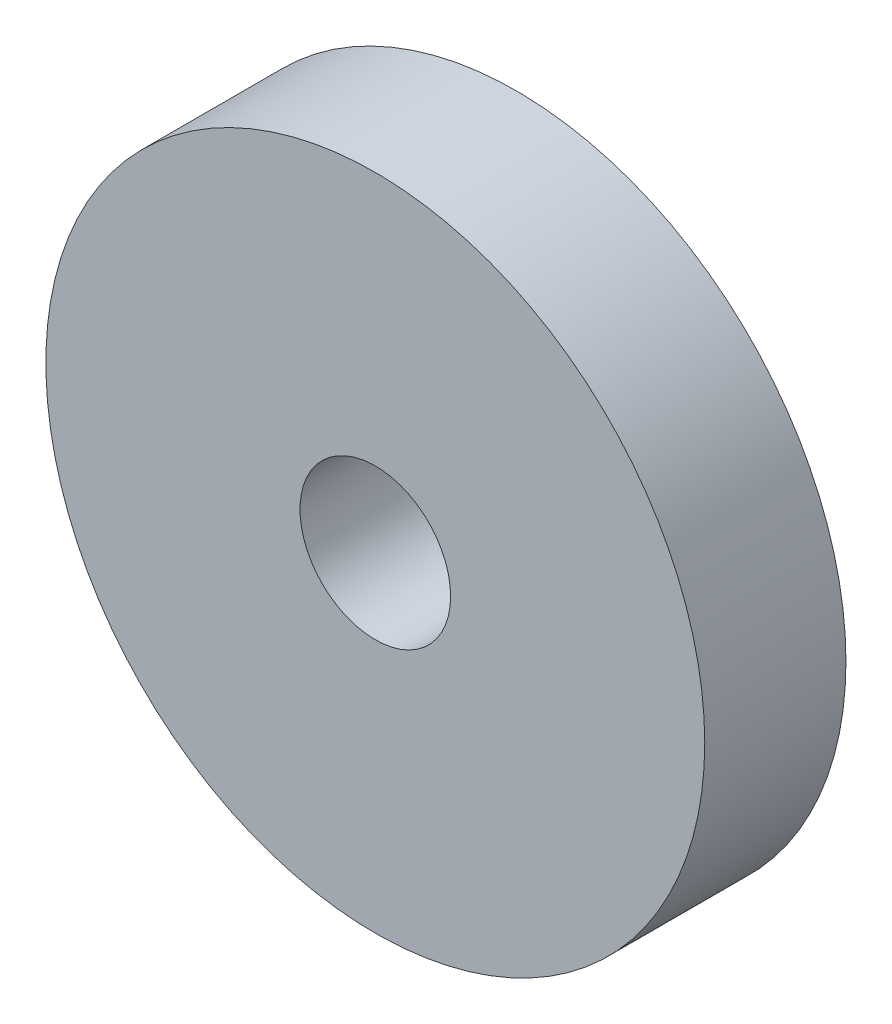
from build123d import *

# Parameters (mm, degrees)
SKETCH1_R           = 7
BOSS_EXTRUDE1_DEPTH = 3
SKETCH2_R           = 1.6
CUT_EXTRUDE1_DEPTH  = 3


with BuildPart() as part:
    # Sketch1 → Boss-Extrude1 (new body)
    with BuildSketch(Plane.XY):
        Circle(SKETCH1_R)
    extrude(amount=BOSS_EXTRUDE1_DEPTH)

    # Sketch2 → Cut-Extrude1 (cut)
    with BuildSketch(Plane.XY.offset(3)):
        Circle(SKETCH2_R)
    extrude(amount=-CUT_EXTRUDE1_DEPTH, mode=Mode.SUBTRACT)


solid = part.part
